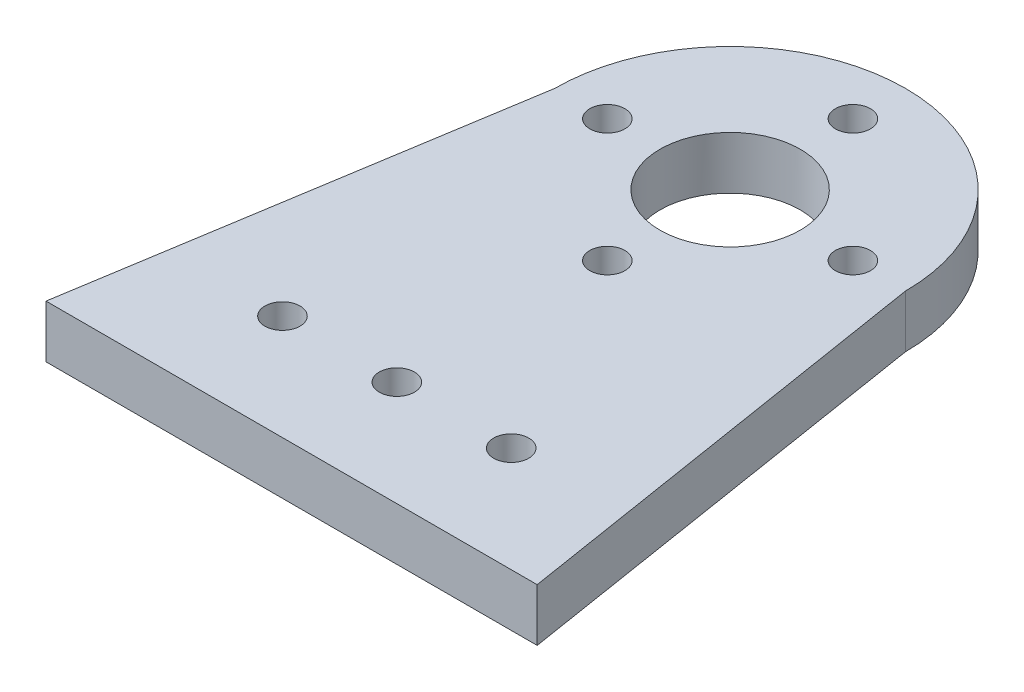
from build123d import *

# Parameters (mm, degrees)
BOSS_EXTRUDE1_DEPTH = 3
SKETCH2_R           = 4
CUT_EXTRUDE1_DEPTH  = 13
SKETCH3_R           = 1
CUT_EXTRUDE2_DEPTH  = 13
SKETCH4_R           = 1
CUT_EXTRUDE3_DEPTH  = 3


with BuildPart() as part:
    # Sketch1 → Boss-Extrude1 (new body)
    with BuildSketch(Plane(origin=(0, 0, 0), x_dir=(1, 0, 0), z_dir=(0, 1, 0))):
        with BuildLine():
            Line((-10, 0), (-14, -25))
            Line((-14, -25), (14, -25))
            Line((14, -25), (10, 0))
            ThreePointArc((10, 0), (0, 10), (-10, 0))
        make_face()
    extrude(amount=BOSS_EXTRUDE1_DEPTH)

    # Sketch2 → Cut-Extrude1 (cut)
    with BuildSketch(Plane(origin=(0, 3, 0), x_dir=(1, 0, 0), z_dir=(0, 1, 0))):
        Circle(SKETCH2_R)
    extrude(amount=-CUT_EXTRUDE1_DEPTH, mode=Mode.SUBTRACT)

    # Sketch3 → Cut-Extrude2 (cut)
    with BuildSketch(Plane(origin=(0, 3, 0), x_dir=(1, 0, 0), z_dir=(0, 1, 0))):
        with Locations((-6.52, -19)):
            Circle(SKETCH3_R)
        with Locations((6.52, -19)):
            Circle(SKETCH3_R)
        with Locations((0, -19)):
            Circle(SKETCH3_R)
    extrude(amount=-CUT_EXTRUDE2_DEPTH, mode=Mode.SUBTRACT)

    # Sketch4 → Cut-Extrude3 (cut)
    with BuildSketch(Plane(origin=(0, 3, 0), x_dir=(1, 0, 0), z_dir=(0, 1, 0))):
        with Locations((0, -7)):
            Circle(SKETCH4_R)
        with Locations((-7, 0)):
            Circle(SKETCH4_R)
        with Locations((0, 7)):
            Circle(SKETCH4_R)
        with Locations((7, 0)):
            Circle(SKETCH4_R)
    extrude(amount=-CUT_EXTRUDE3_DEPTH, mode=Mode.SUBTRACT)


solid = part.part
